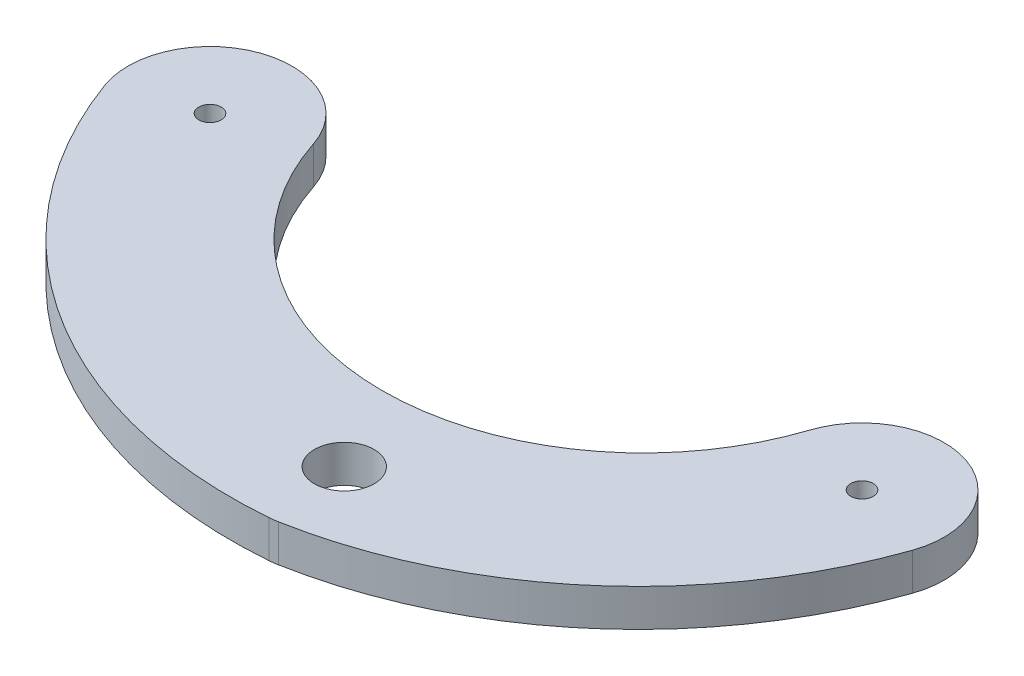
from build123d import *

# Parameters (mm, degrees)
SKETCH2_R           = 4
SKETCH2_R_2         = 1.5
BOSS_EXTRUDE1_DEPTH = 5


with BuildPart() as part:
    # Sketch2 → Boss-Extrude1 (new body)
    with BuildSketch(Plane(origin=(0, 0, 0), x_dir=(1, 0, 0), z_dir=(0, 1, 0))):
        with BuildLine():
            ThreePointArc((76.95, 3.434748899), (43.7, -20.636504604), (10.45, 3.434748899))
            ThreePointArc((10.45, 3.434748899), (-3.607827445, 10.391514862), (-10.330163324, -3.779910806))
            ThreePointArc((-10.330163324, -3.779910806), (13.672960294, -33.698499541), (50.894326472, -42.963584275))
            ThreePointArc((50.894326472, -42.963584275), (51.441931195, -42.905082963), (51.985921637, -42.819247444))
            ThreePointArc((51.985921637, -42.819247444), (80.160934451, -29.394967139), (97.781840004, -3.635573974))
            ThreePointArc((97.781840004, -3.635573974), (90.935325704, 10.416403994), (76.95, 3.434748899))
        make_face()
        with Locations((50, -32)):
            Circle(SKETCH2_R, mode=Mode.SUBTRACT)
        Circle(SKETCH2_R_2, mode=Mode.SUBTRACT)
        with Locations((87.4, 0)):
            Circle(SKETCH2_R_2, mode=Mode.SUBTRACT)
    extrude(amount=BOSS_EXTRUDE1_DEPTH)


solid = part.part
